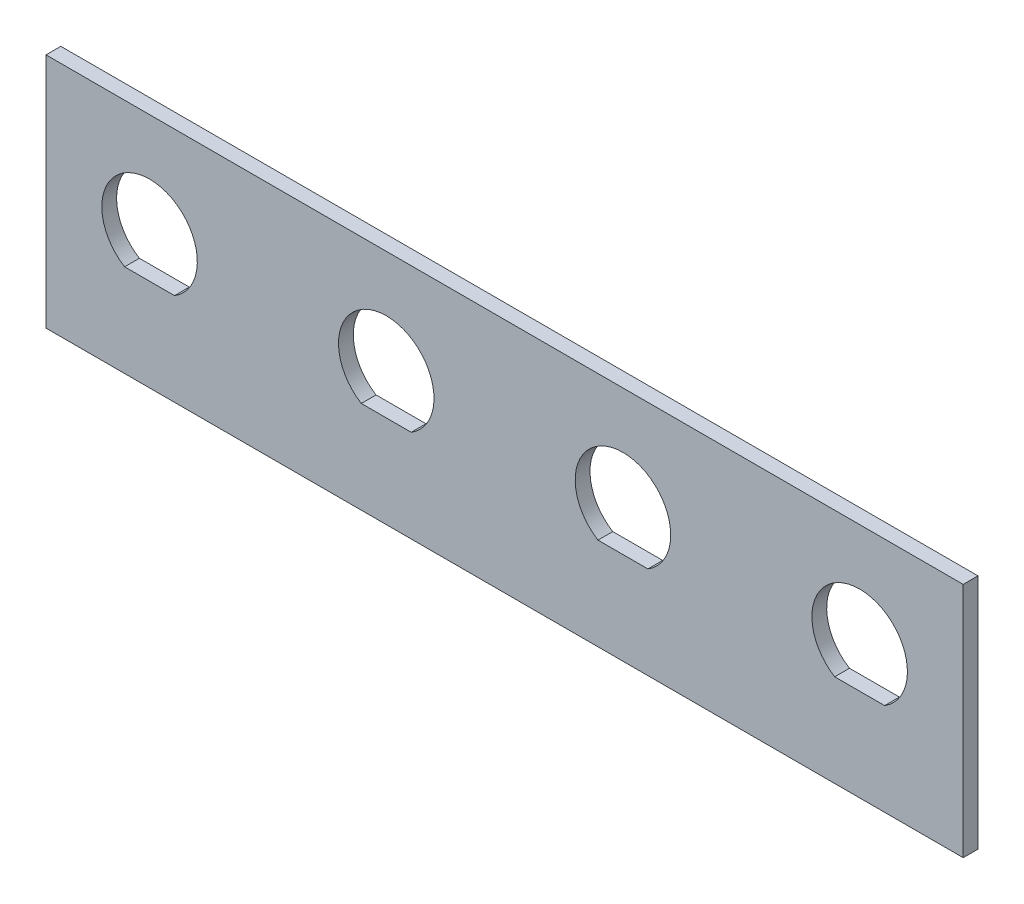
from build123d import *

# Parameters (mm, degrees)
SKETCH1_W           = 203.2
SKETCH1_H           = 127
BOSS_EXTRUDE1_DEPTH = 50.8
SKETCH2_W           = 196.85
SKETCH2_H           = 120.65
CUT_EXTRUDE1_DEPTH  = 51.8
SKETCH4_W           = 203.2
SKETCH4_H           = 127
SKETCH4_W_2         = 196.85
SKETCH4_H_2         = 120.65
BOSS_EXTRUDE2_DEPTH = 6.35
CUT_EXTRUDE5_DEPTH  = 128
CUT_EXTRUDE6_REACH  = 205.2
CUT_EXTRUDE7_REACH  = 205.2
SKETCH13_R          = 12.55395
CUT_EXTRUDE8_DEPTH  = 51.8


with BuildPart() as part:
    # Sketch1 → Boss-Extrude1 (new body)
    with BuildSketch(Plane(origin=(0, 0, 0), x_dir=(1, 0, 0), z_dir=(0, 1, 0))):
        Rectangle(SKETCH1_W, SKETCH1_H)
    extrude(amount=BOSS_EXTRUDE1_DEPTH)

    # Sketch2 → Cut-Extrude1 (cut, through all)
    with BuildSketch(Plane(origin=(0, 50.8, 0), x_dir=(1, 0, 0), z_dir=(0, 1, 0))):
        Rectangle(SKETCH2_W, SKETCH2_H)
    extrude(amount=-CUT_EXTRUDE1_DEPTH, mode=Mode.SUBTRACT)

    # Sketch4 → Boss-Extrude2 (add)
    with BuildSketch(Plane(origin=(0, 50.8, 0), x_dir=(1, 0, 0), z_dir=(0, 1, 0))):
        Rectangle(SKETCH4_W, SKETCH4_H)
        Rectangle(SKETCH4_W_2, SKETCH4_H_2, mode=Mode.SUBTRACT)
    extrude(amount=-BOSS_EXTRUDE2_DEPTH)

    # Sketch10 → Cut-Extrude5 (cut, through all)
    with BuildSketch(Plane.XY.offset(63.5)):
        with BuildLine():
            ThreePointArc((-70.843294161, 19.8374), (-76.2, 38.8239), (-81.556705839, 19.8374))
            Line((-81.556705839, 19.8374), (-70.843294161, 19.8374))
        make_face()
        with BuildLine():
            ThreePointArc((81.556705839, 19.8374), (76.2, 38.8239), (70.843294161, 19.8374))
            Line((70.843294161, 19.8374), (81.556705839, 19.8374))
        make_face()
        with BuildLine():
            ThreePointArc((30.756705839, 19.8374), (25.4, 38.8239), (20.043294161, 19.8374))
            Line((20.043294161, 19.8374), (30.756705839, 19.8374))
        make_face()
        with BuildLine():
            ThreePointArc((-20.043294161, 19.8374), (-25.4, 38.8239), (-30.756705839, 19.8374))
            Line((-30.756705839, 19.8374), (-20.043294161, 19.8374))
        make_face()
    extrude(amount=-CUT_EXTRUDE5_DEPTH, mode=Mode.SUBTRACT)

    # Sketch12 → Cut-Extrude6 (cut, up to next)
    with BuildSketch(Plane(origin=(101.6, 0, 0), x_dir=(0, 0, -1), z_dir=(1, 0, 0)), mode=Mode.PRIVATE) as cut_extrude6_sk1:
        with BuildLine():
            ThreePointArc((-20.043294161, 19.8374), (-25.4, 38.8239), (-30.756705839, 19.8374))
            Line((-30.756705839, 19.8374), (-20.043294161, 19.8374))
        make_face()
    cut_extrude6_tool1 = extrude(cut_extrude6_sk1.sketch, amount=-CUT_EXTRUDE6_REACH, mode=Mode.PRIVATE) & part.part
    add(cut_extrude6_tool1.solids().sort_by_distance((101.6, 28.896198, 25.4))[0], mode=Mode.SUBTRACT)
    # Sketch12 → Cut-Extrude6 (cut, up to next)
    with BuildSketch(Plane(origin=(101.6, 0, 0), x_dir=(0, 0, -1), z_dir=(1, 0, 0)), mode=Mode.PRIVATE) as cut_extrude6_sk2:
        with BuildLine():
            ThreePointArc((30.756705839, 19.8374), (25.4, 38.8239), (20.043294161, 19.8374))
            Line((20.043294161, 19.8374), (30.756705839, 19.8374))
        make_face()
    cut_extrude6_tool2 = extrude(cut_extrude6_sk2.sketch, amount=-CUT_EXTRUDE6_REACH, mode=Mode.PRIVATE) & part.part
    add(cut_extrude6_tool2.solids().sort_by_distance((101.6, 28.896198, -25.4))[0], mode=Mode.SUBTRACT)

    # Sketch13 → Cut-Extrude7 (cut, up to next)
    with BuildSketch(Plane.ZY.offset(101.6), mode=Mode.PRIVATE) as cut_extrude7_sk1:
        with Locations((12.7, 28.575)):
            Circle(SKETCH13_R)
    cut_extrude7_tool1 = extrude(cut_extrude7_sk1.sketch, amount=-CUT_EXTRUDE7_REACH, mode=Mode.PRIVATE) & part.part
    add(cut_extrude7_tool1.solids().sort_by_distance((-101.6, 28.575, 12.7))[0], mode=Mode.SUBTRACT)

    # Sketch14 → Cut-Extrude8 (cut, through all)
    with BuildSketch(Plane(origin=(0, 50.8, 0), x_dir=(1, 0, 0), z_dir=(0, 1, 0))):
        Polygon((-98.425, -60.325), (-98.425, -63.5), (-101.6, -63.5), (-101.6, 63.5), (101.6, 63.5), (101.6, -63.5), (98.425, -63.5), (98.425, -60.325), align=None)
    extrude(amount=-CUT_EXTRUDE8_DEPTH, mode=Mode.SUBTRACT)


solid = part.part
